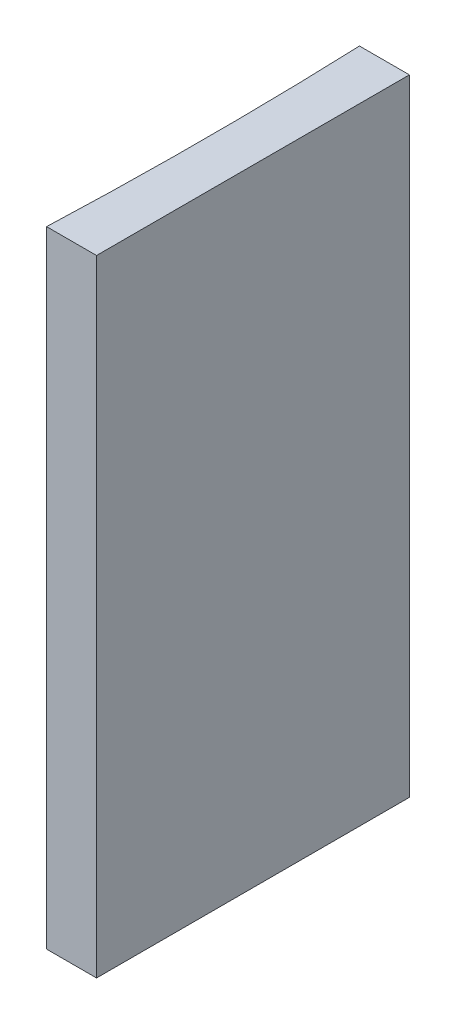
from build123d import *

# Parameters (mm, degrees)
EXTRUDE_1_DEPTH = 40


with BuildPart() as part:
    # 草图1 → 凸台-拉伸1 (new body)
    with BuildSketch(Plane(origin=(0, 0, 0), x_dir=(1, 0, 0), z_dir=(0, 1, 0))):
        with BuildLine():
            Line((0, 0), (0, -20))
            Line((0, -20), (-3.193496017, -20))
            ThreePointArc((-3.193496017, -20), (-3, -10), (-3.193496017, 0))
            Line((-3.193496017, 0), (0, 0))
        make_face()
    extrude(amount=EXTRUDE_1_DEPTH)


solid = part.part
